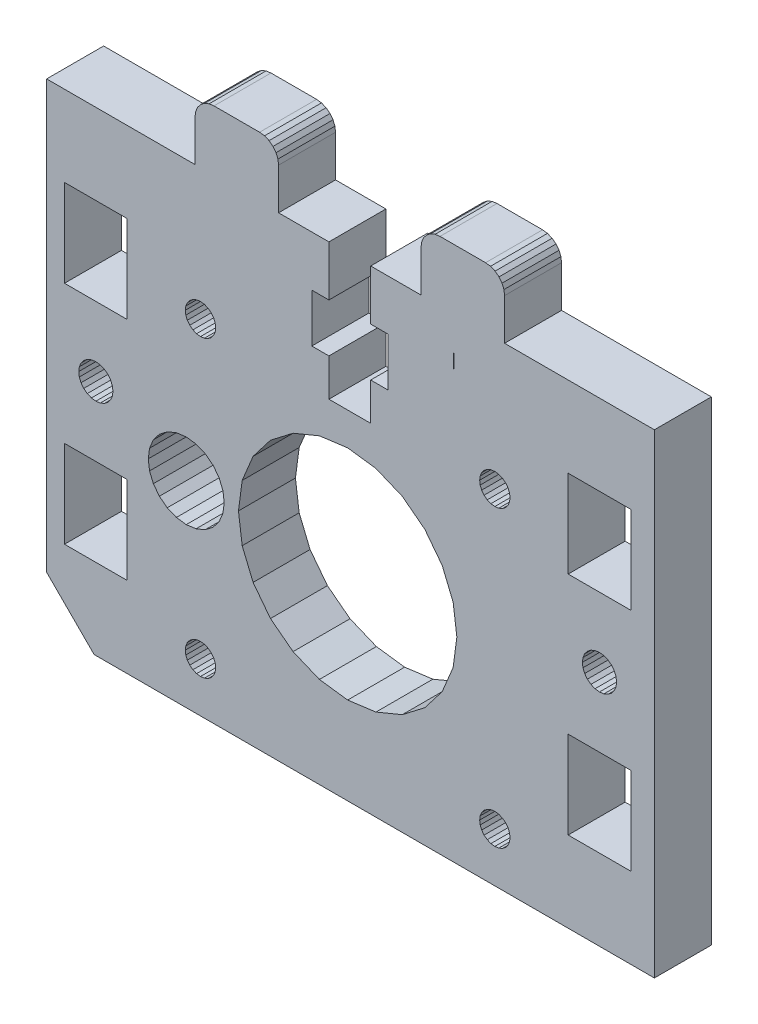
from build123d import *

# Parameters (mm, degrees)
SKETCH1_W           = 6.599987016
SKETCH1_H           = 9.199995837
SKETCH1_W_2         = 6.600001918
SKETCH1_H_2         = 9.1999977
BOSS_EXTRUDE1_DEPTH = 6


with BuildPart() as part:
    # Sketch1 → Boss-Extrude1 (new body)
    with BuildSketch(Plane.XY):
        Polygon((301.953663049, 85.092507176), (301.953663049, 79.792508354), (303.753661281, 79.792508354), (303.753661281, 74.69251059), (301.953663049, 74.69251059), (301.953663049, 70.742510767), (297.553658377, 70.742510767), (297.553658377, 74.69251059), (295.753660146, 74.69251059), (295.753660146, 79.792508354), (297.553658377, 79.792508354), (297.553658377, 85.092507176), (292.253661123, 85.092507176), (292.253661123, 89.442505067), (292.185512775, 89.960143157), (291.98571193, 90.442505067), (291.667874685, 90.856718629), (291.253661123, 91.174555875), (290.771299213, 91.37435672), (290.253661123, 91.442505067), (285.45366668, 91.442505067), (284.93602859, 91.37435672), (284.45366668, 91.174555875), (284.039453118, 90.856718629), (283.721615873, 90.442505067), (283.521815028, 89.960143157), (283.45366668, 89.442505067), (283.45366668, 85.092507176), (267.828679289, 85.092507176), (267.828679289, 40.092521493), (272.828677689, 35.092523093), (331.828652368, 35.092523093), (331.828647252, 85.092507176), (316.053651021, 85.092507176), (316.053651021, 89.442505067), (315.985502674, 89.960143157), (315.785701829, 90.442505067), (315.467864583, 90.856718629), (315.053651021, 91.174555875), (314.571289111, 91.37435672), (314.053651021, 91.442505067), (309.253655056, 91.442505067), (308.736016966, 91.37435672), (308.253655056, 91.174555875), (307.839441494, 90.856718629), (307.521604248, 90.442505067), (307.321803403, 89.960143157), (307.253655056, 89.442505067), (307.253655056, 85.092507176), align=None)
        with Locations((326.048652588, 71.99251115)):
            Rectangle(SKETCH1_W, SKETCH1_H, mode=Mode.SUBTRACT)
        Polygon((288.420519025, 52.816098409), (288.028666153, 55.792516475), (288.420519025, 58.768934541), (289.569373516, 61.542514635), (291.396937091, 63.924241857), (293.778664313, 65.751805432), (296.552244407, 66.900659923), (299.528662473, 67.292512795), (302.505080539, 66.900659923), (305.278660633, 65.751805432), (307.660387854, 63.924241857), (309.487951429, 61.542514635), (310.636805921, 58.768934541), (311.028658793, 55.792516475), (310.636805921, 52.816098409), (309.487951429, 50.042518315), (307.660387854, 47.660791094), (305.278660633, 45.833227519), (302.505080539, 44.684373027), (299.528662473, 44.292520155), (296.552244407, 44.684373027), (293.778664313, 45.833227519), (291.396937091, 47.660791094), (289.569373516, 50.042518315), align=None, mode=Mode.SUBTRACT)
        Polygon((283.614557093, 72.837992343), (284.028667433, 72.892511003), (284.442777773, 72.837992343), (284.828667177, 72.678151718), (285.160037921, 72.423882003), (285.414307636, 72.092511259), (285.57414826, 71.706621855), (285.628666921, 71.292511515), (285.57414826, 70.878401175), (285.414307636, 70.492511771), (285.160037921, 70.161141027), (284.828667177, 69.906871312), (284.442777773, 69.747030688), (284.028667433, 69.692512027), (283.614557093, 69.747030688), (283.228667689, 69.906871312), (282.897296945, 70.161141027), (282.64302723, 70.492511771), (282.483186605, 70.878401175), (282.428667945, 71.292511515), (282.483186605, 71.706621855), (282.64302723, 72.092511259), (282.897296945, 72.423882003), (283.228667689, 72.678151718), align=None, mode=Mode.SUBTRACT)
        Polygon((327.322666584, 61.366527217), (327.608994274, 60.993377707), (327.788987384, 60.558835899), (327.850379682, 60.092515099), (327.788987384, 59.626194299), (327.608994274, 59.191652491), (327.322666584, 58.818502981), (326.949517074, 58.532175292), (326.514975266, 58.352182182), (326.048654466, 58.290789884), (325.582333667, 58.352182182), (325.147791859, 58.532175292), (324.774642349, 58.818502981), (324.488314659, 59.191652491), (324.308321549, 59.626194299), (324.246929251, 60.092515099), (324.308321549, 60.558835899), (324.488314659, 60.993377707), (324.774642349, 61.366527217), (325.147791859, 61.652854906), (325.582333667, 61.832848017), (326.048654466, 61.894240315), (326.514975266, 61.832848017), (326.949517074, 61.652854906), align=None, mode=Mode.SUBTRACT)
        Polygon((285.992768419, 53.792517115), (285.357094133, 52.964090255), (284.528667273, 52.328415968), (283.563943762, 51.928814406), (282.528667913, 51.792517755), (281.493392064, 51.928814406), (280.528668553, 52.328415968), (279.700241693, 52.964090255), (279.064567406, 53.792517115), (278.664965844, 54.757240626), (278.528669193, 55.792516475), (278.664965844, 56.827792324), (279.064567406, 57.792515835), (279.700241693, 58.620942695), (280.528668553, 59.256616982), (281.493392064, 59.656218544), (282.528667913, 59.792515195), (283.563943762, 59.656218544), (284.528667273, 59.256616982), (285.357094133, 58.620942695), (285.992768419, 57.792515835), (286.392369982, 56.827792324), (286.528666633, 55.792516475), (286.392369982, 54.757240626), align=None, mode=Mode.SUBTRACT)
        Polygon((315.442767853, 69.747030688), (315.028657513, 69.692512027), (314.614547173, 69.747030688), (314.228657769, 69.906871312), (313.897287025, 70.161141027), (313.64301731, 70.492511771), (313.483176685, 70.878401175), (313.428658025, 71.292511515), (313.483176685, 71.706621855), (313.64301731, 72.092511259), (313.897287025, 72.423882003), (314.228657769, 72.678151718), (314.614547173, 72.837992343), (315.028657513, 72.892511003), (315.442767853, 72.837992343), (315.828657257, 72.678151718), (316.160028001, 72.423882003), (316.414297716, 72.092511259), (316.57413834, 71.706621855), (316.628657001, 71.292511515), (316.57413834, 70.878401175), (316.414297716, 70.492511771), (316.160028001, 70.161141027), (315.828657257, 69.906871312), align=None, mode=Mode.SUBTRACT)
        Polygon((283.614557093, 41.838002263), (284.028667433, 41.892520923), (284.442777773, 41.838002263), (284.828667177, 41.678161638), (285.160037921, 41.423891923), (285.414307636, 41.092521179), (285.57414826, 40.706631775), (285.628666921, 40.292521435), (285.57414826, 39.878411095), (285.414307636, 39.492521691), (285.160037921, 39.161150947), (284.828667177, 38.906881232), (284.442777773, 38.747040608), (284.028667433, 38.692521947), (283.614557093, 38.747040608), (283.228667689, 38.906881232), (282.897296945, 39.161150947), (282.64302723, 39.492521691), (282.483186605, 39.878411095), (282.428667945, 40.292521435), (282.483186605, 40.706631775), (282.64302723, 41.092521179), (282.897296945, 41.423891923), (283.228667689, 41.678161638), align=None, mode=Mode.SUBTRACT)
        Polygon((315.828657257, 38.906881232), (315.442767853, 38.747040608), (315.028657513, 38.692521947), (314.614547173, 38.747040608), (314.228657769, 38.906881232), (313.897287025, 39.161150947), (313.64301731, 39.492521691), (313.483176685, 39.878411095), (313.428658025, 40.292521435), (313.483176685, 40.706631775), (313.64301731, 41.092521179), (313.897287025, 41.423891923), (314.228657769, 41.678161638), (314.614547173, 41.838002263), (315.028657513, 41.892520923), (315.442767853, 41.838002263), (315.828657257, 41.678161638), (316.160028001, 41.423891923), (316.414297716, 41.092521179), (316.57413834, 40.706631775), (316.628657001, 40.292521435), (316.57413834, 39.878411095), (316.414297716, 39.492521691), (316.160028001, 39.161150947), align=None, mode=Mode.SUBTRACT)
        with Locations((273.00867144, 71.99251115)):
            Rectangle(SKETCH1_W_2, SKETCH1_H, mode=Mode.SUBTRACT)
        with Locations((273.00867144, 48.19252032)):
            Rectangle(SKETCH1_W_2, SKETCH1_H_2, mode=Mode.SUBTRACT)
        Polygon((271.268337562, 60.558835899), (271.448330672, 60.993377707), (271.734658361, 61.366527217), (272.107807871, 61.652854906), (272.542349679, 61.832848017), (273.008670479, 61.894240315), (273.474991279, 61.832848017), (273.909533087, 61.652854906), (274.282682597, 61.366527217), (274.569010287, 60.993377707), (274.749003397, 60.558835899), (274.810395695, 60.092515099), (274.749003397, 59.626194299), (274.569010287, 59.191652491), (274.282682597, 58.818502981), (273.909533087, 58.532175292), (273.474991279, 58.352182182), (273.008670479, 58.290789884), (272.542349679, 58.352182182), (272.107807871, 58.532175292), (271.734658361, 58.818502981), (271.448330672, 59.191652491), (271.268337562, 59.626194299), (271.206945264, 60.092515099), align=None, mode=Mode.SUBTRACT)
        with Locations((326.048652588, 48.19252032)):
            Rectangle(SKETCH1_W, SKETCH1_H_2, mode=Mode.SUBTRACT)
        Polygon((310.697684958, 81.50053754), (310.7177819, 81.596725969), (310.697684958, 79.827328698), align=None, mode=Mode.SUBTRACT)
    extrude(amount=BOSS_EXTRUDE1_DEPTH)


solid = part.part
